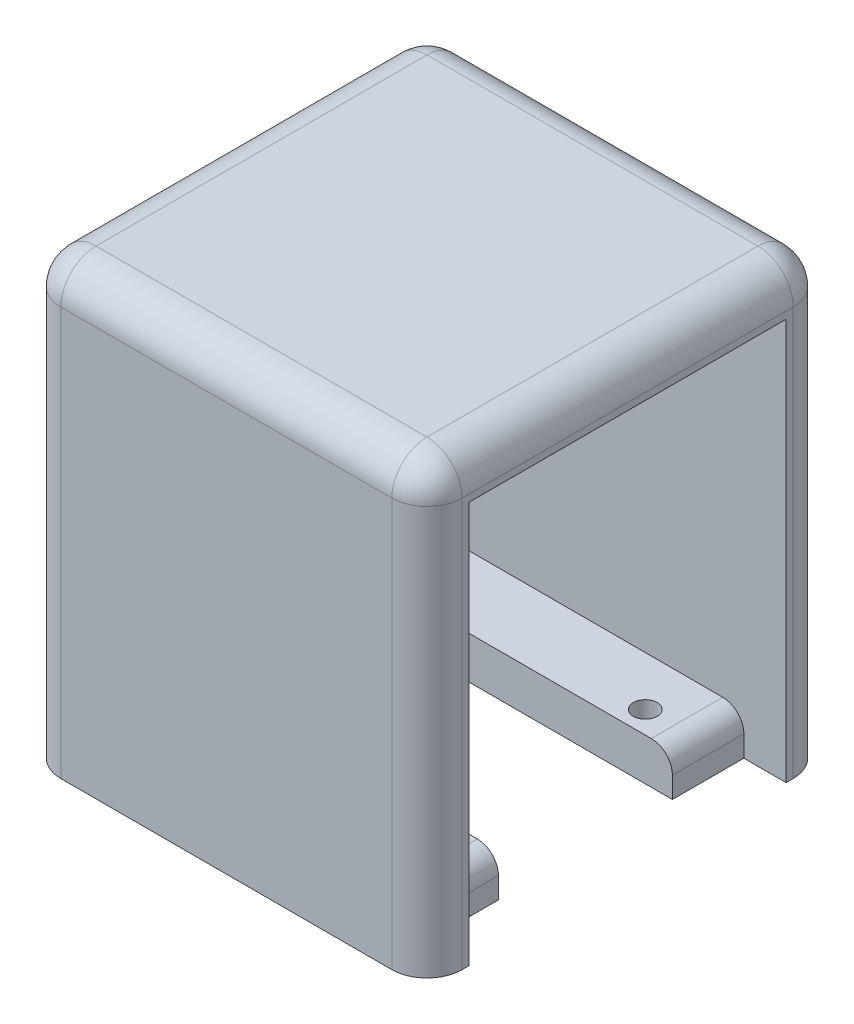
from build123d import *

# Parameters (mm, degrees)
SKETCH1_W                 = 57
SKETCH1_H                 = 57
BOSS_EXTRUDE3_DEPTH       = 63
SKETCH3_W                 = 45
SKETCH3_H                 = 57
CUT_EXTRUDE2_DEPTH        = 29.5
CUT_EXTRUDE2_DEPTH_BACK   = 22.5
BOSS_EXTRUDE4_DEPTH       = 6
F_5_0MM_DOWEL_HOLE1_D     = 3.4
F_5_0MM_DOWEL_HOLE1_DEPTH = 6
F_5_0MM_DOWEL_HOLE1_TIP   = 1.021463052
FILLET1_R                 = 5
FILLET2_R                 = 3


with BuildPart() as part:
    # Sketch1 → Boss-Extrude3 (new body)
    with BuildSketch(Plane(origin=(0, 0, 0), x_dir=(1, 0, 0), z_dir=(0, 1, 0))):
        Rectangle(SKETCH1_W, SKETCH1_H)
    extrude(amount=BOSS_EXTRUDE3_DEPTH)

    # Sketch3 → Cut-Extrude2 (cut, two sides)
    with BuildSketch(Plane(origin=(0, 0, 0), x_dir=(0, 0, -1), z_dir=(1, 0, 0))) as cut_extrude2_sk:
        with Locations((0, 28.5)):
            Rectangle(SKETCH3_W, SKETCH3_H)
    extrude(amount=CUT_EXTRUDE2_DEPTH, mode=Mode.SUBTRACT)
    extrude(cut_extrude2_sk.sketch, amount=-CUT_EXTRUDE2_DEPTH_BACK, mode=Mode.SUBTRACT)

    # Sketch1_6 → Boss-Extrude4 (add)
    with BuildSketch(Plane(origin=(0, 0, 0), x_dir=(1, 0, 0), z_dir=(0, 1, 0))):
        Polygon((22.5, 22.5), (-22.5, 22.5), (-22.5, -22.5), (22.5, -22.5), (22.5, -12.350491759), (-12.350491759, -12.350491759), (-12.350491759, 12.350491759), (22.5, 12.350491759), align=None)
    extrude(amount=BOSS_EXTRUDE4_DEPTH)

    # Ø5.0mm Dowel Hole1
    with Locations(Plane(origin=(0, 0, 0), x_dir=(-1, 0, 0), z_dir=(0, -1, 0))):
        with Locations((15.5, -15.5), (15.5, 15.5), (-15.5, 15.5), (-15.5, -15.5)):
            Hole(F_5_0MM_DOWEL_HOLE1_D / 2, depth=F_5_0MM_DOWEL_HOLE1_DEPTH)
            with Locations((0, 0, -(F_5_0MM_DOWEL_HOLE1_DEPTH + F_5_0MM_DOWEL_HOLE1_TIP / 2))):  # 118° drill point
                Cone(0, F_5_0MM_DOWEL_HOLE1_D / 2, F_5_0MM_DOWEL_HOLE1_TIP, mode=Mode.SUBTRACT)

    # Fillet1
    fillet1_edges = [part.edges().sort_by_distance(p)[0] for p in [
        (0, 63, -28.5),
        (-28.5, 63, 0),
        (0, 63, 28.5),
        (28.5, 63, 0),
        (28.5, 31.5, 28.5),
        (-28.5, 31.5, 28.5),
        (-28.5, 31.5, -28.5),
        (28.5, 31.5, -28.5),
    ]]
    fillet(fillet1_edges, radius=FILLET1_R)

    # Fillet2
    fillet2_edges = [part.edges().sort_by_distance(p)[0] for p in [
        (22.5, 6, -17.425245879),
        (22.5, 6, 17.425245879),
    ]]
    fillet(fillet2_edges, radius=FILLET2_R)


solid = part.part
